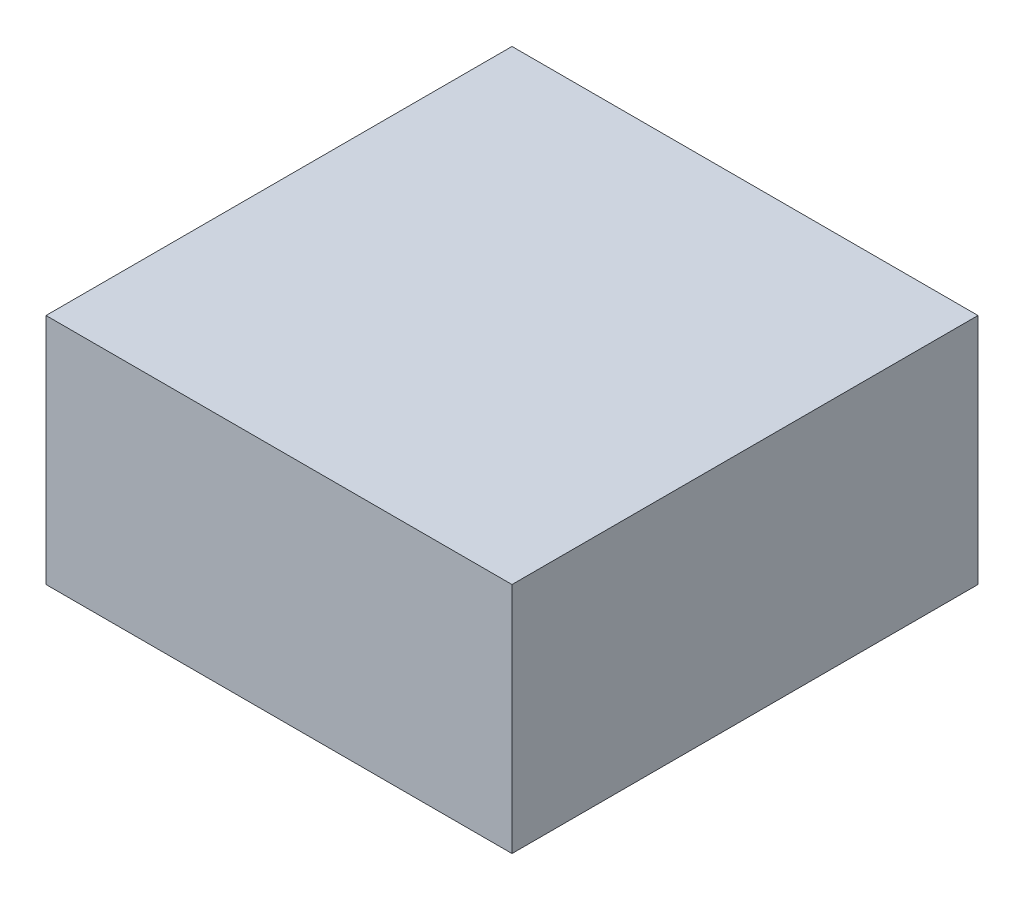
from build123d import *

# Parameters (mm, degrees)
SKETCH1_W           = 10
SKETCH1_H           = 10
BOSS_EXTRUDE1_DEPTH = 5


with BuildPart() as part:
    # Sketch1 → Boss-Extrude1 (new body)
    with BuildSketch(Plane(origin=(0, 0, 0), x_dir=(1, 0, 0), z_dir=(0, 1, 0))):
        with Locations((5, 5)):
            Rectangle(SKETCH1_W, SKETCH1_H)
    extrude(amount=BOSS_EXTRUDE1_DEPTH)


solid = part.part
